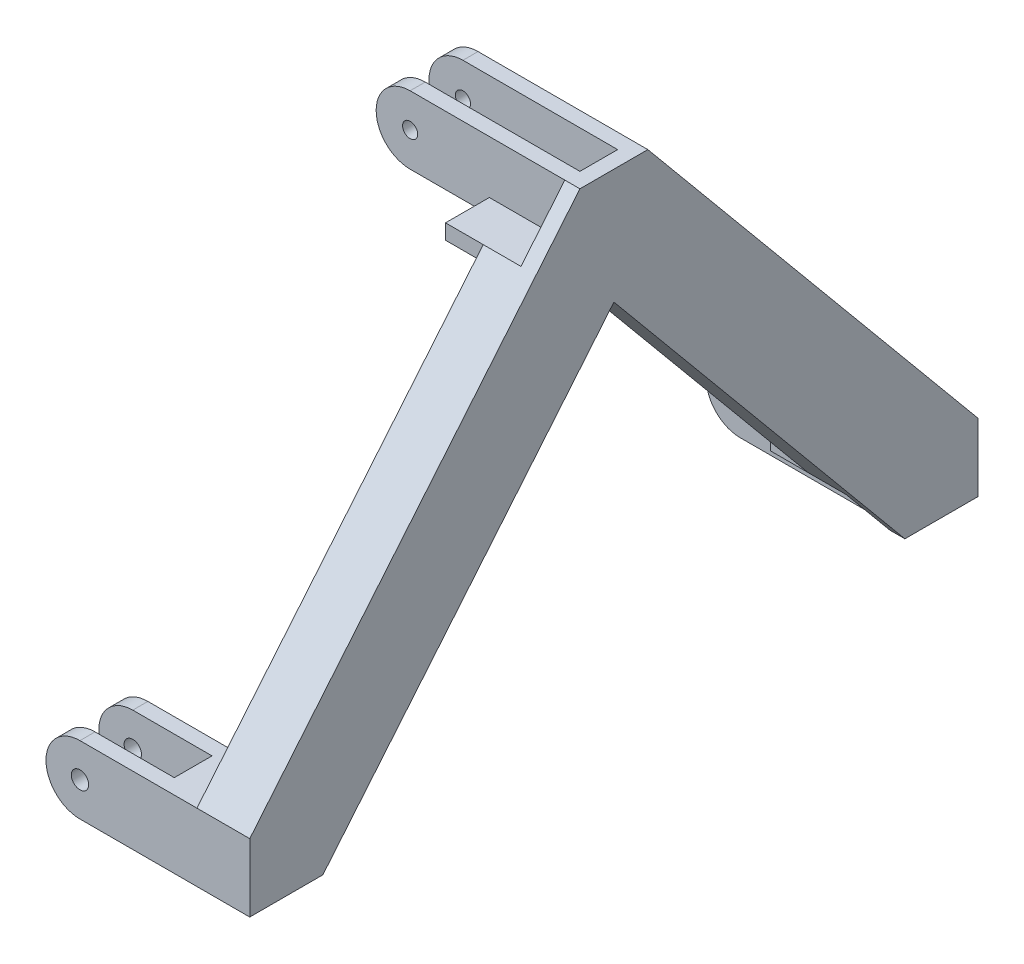
from build123d import *

# Parameters (mm, degrees)
BOSS_EXTRUDE1_DEPTH     = 100
BOSS_EXTRUDE1_2_DEPTH   = 100
BOSS_EXTRUDE1_3_DEPTH   = 100
SKETCH2_W               = 20
SKETCH2_H               = 90
BOSS_EXTRUDE2_DEPTH     = 150
BOSS_EXTRUDE3_DEPTH     = 20
SKETCH4_R               = 11.5
SKETCH4_R_2             = 10
CUT_EXTRUDE2_DEPTH      = 1
CUT_EXTRUDE2_DEPTH_BACK = 966
BOSS_EXTRUDE4_DEPTH     = 50
BOSS_EXTRUDE5_DEPTH     = 10


with BuildPart() as part:
    # Sketch1 → Boss-Extrude1 (new body)
    with BuildSketch(Plane(origin=(0, 0, 0), x_dir=(0, 0, -1), z_dir=(1, 0, 0))):
        Polygon((-462.5, 0), (-412.5, 0), (-412.5, -70), (-392.5, -70), (-392.5, 0), (-327.5, 0), (-327.5, 20), (-482.5, 20), (-482.5, -70), (-462.5, -70), align=None)
    extrude(amount=BOSS_EXTRUDE1_DEPTH)



with BuildPart() as body_2:
    # Sketch1 → Boss-Extrude1 2 (new body)
    with BuildSketch(Plane(origin=(0, 0, 0), x_dir=(0, 0, -1), z_dir=(1, 0, 0))):
        Polygon((25, 477), (-25, 477), (-25, 547), (-45, 547), (-45, 477), (-103.111954459, 477), (-103.111954459, 457), (103.111954459, 457), (103.111954459, 477), (45, 477), (45, 547), (25, 547), align=None)
    extrude(amount=BOSS_EXTRUDE1_2_DEPTH)


with BuildPart() as body_3:
    # Sketch1 → Boss-Extrude1 3 (new body)
    with BuildSketch(Plane(origin=(0, 0, 0), x_dir=(0, 0, -1), z_dir=(1, 0, 0))):
        Polygon((392.5, 0), (327.5, 0), (327.5, 20), (482.5, 20), (482.5, -70), (462.5, -70), (462.5, 0), (412.5, 0), (412.5, -70), (392.5, -70), align=None)
    extrude(amount=BOSS_EXTRUDE1_3_DEPTH)


with BuildPart() as part_1:
    add(part.part)

    add(body_2.part)  # Boss-Extrude2 merges body 2

    add(body_3.part)  # Boss-Extrude2 merges body 3
    # Sketch2 → Boss-Extrude2 (add)
    with BuildSketch(Plane.ZY):
        with Locations((-472.5, -25)):
            Rectangle(SKETCH2_W, SKETCH2_H)
        with Locations((-402.5, -25)):
            Rectangle(SKETCH2_W, SKETCH2_H)
        with Locations((-35, 502)):
            Rectangle(SKETCH2_W, SKETCH2_H)
        with Locations((35, 502)):
            Rectangle(SKETCH2_W, SKETCH2_H)
        with Locations((402.5, -25)):
            Rectangle(SKETCH2_W, SKETCH2_H)
        with Locations((472.5, -25)):
            Rectangle(SKETCH2_W, SKETCH2_H)
    extrude(amount=BOSS_EXTRUDE2_DEPTH)

    # Sketch3 → Boss-Extrude3 (add)
    with BuildSketch(Plane(origin=(100, 0, 0), x_dir=(0, 0, -1), z_dir=(1, 0, 0))):
        Polygon((-482.5, -70), (-482.5, 20), (-45, 547), (45, 547), (482.5, 20), (482.5, -70), (392.5, -70), (385.611954459, -70), (327.5, 0), (0, 394.497142857), (-327.5, 0), (-385.611954459, -70), (-392.5, -70), align=None)
    extrude(amount=BOSS_EXTRUDE3_DEPTH)

    # Sketch4 → Cut-Extrude2 (cut, two sides)
    with BuildSketch(Plane.XY.offset(482.5)) as cut_extrude2_sk:
        with BuildLine():
            ThreePointArc((-150, -25), (-136.819805153, 6.819805153), (-105, 20))
            Line((-105, 20), (-150, 20))
            Line((-150, 20), (-150, -25))
        make_face()
        with Locations((-105, -25)):
            Circle(SKETCH4_R)
        with BuildLine():
            ThreePointArc((-105, -70), (-136.819805153, -56.819805153), (-150, -25))
            Line((-150, -25), (-150, -70))
            Line((-150, -70), (-105, -70))
        make_face()
        with Locations((-105, 502)):
            Circle(SKETCH4_R_2)
        with BuildLine():
            Line((-150, 547), (-150, 502))
            ThreePointArc((-150, 502), (-136.819805153, 533.819805153), (-105, 547))
            Line((-105, 547), (-150, 547))
        make_face()
        with BuildLine():
            Line((-150, 457), (-105, 457))
            ThreePointArc((-105, 457), (-136.819805153, 470.180194847), (-150, 502))
            Line((-150, 502), (-150, 457))
        make_face()
    extrude(amount=CUT_EXTRUDE2_DEPTH, mode=Mode.SUBTRACT)
    extrude(cut_extrude2_sk.sketch, amount=-CUT_EXTRUDE2_DEPTH_BACK, mode=Mode.SUBTRACT)

    # Sketch5 → Boss-Extrude4 (add)
    with BuildSketch(Plane.ZY.offset(-100)):
        Polygon((-482.5, 20), (-103.111954459, 477), (-103.111954459, 461.344354608), (-469.503140685, 20), align=None)
        Polygon((-327.5, 0), (0, 394.497142857), (327.5, 0), (327.5, 15.655645392), (0, 410.15278825), (-327.5, 15.655645392), align=None)
        Polygon((482.5, 20), (469.503140685, 20), (103.111954459, 461.344354608), (103.111954459, 477), align=None)
    extrude(amount=BOSS_EXTRUDE4_DEPTH)

    # Sketch8 → Boss-Extrude5 (add)
    with BuildSketch(Plane.ZY.offset(-50)):
        Polygon((-482.5, 20), (-327.5, 20), (-327.5, 0), (0, 394.497142857), (327.5, 0), (327.5, 20), (482.5, 20), (103.111954459, 477), (-103.111954459, 477), align=None)
    extrude(amount=-BOSS_EXTRUDE5_DEPTH)


solid = part_1.part
